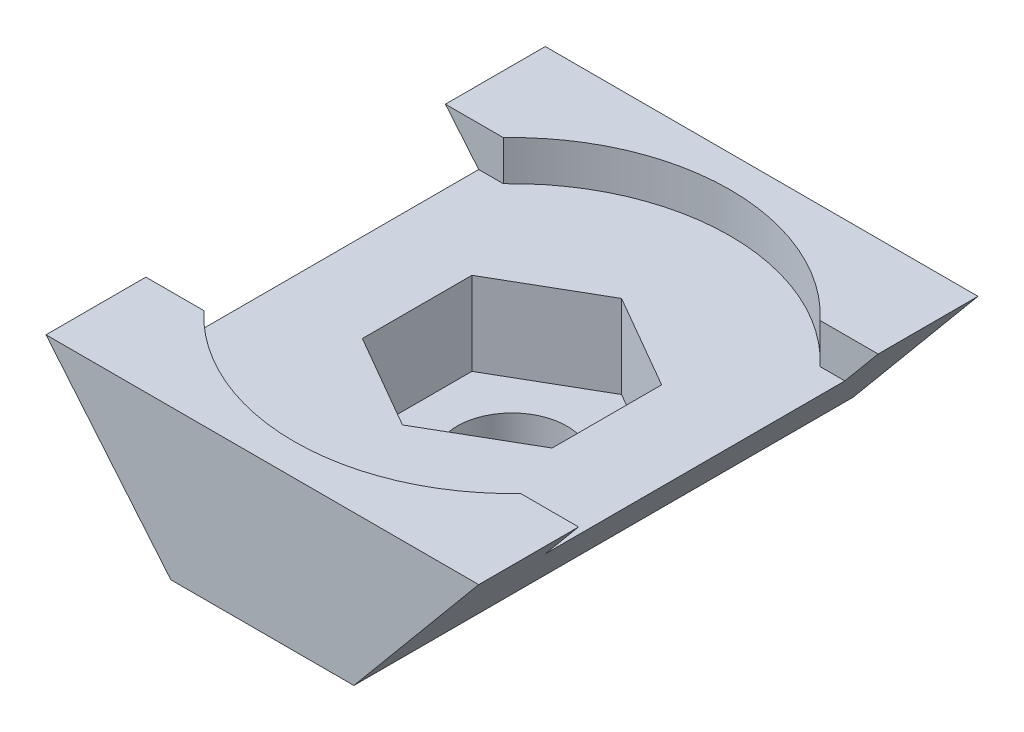
from build123d import *

# Parameters (mm, degrees)
RESSALTO_EXTRUS_O1_DEPTH = 15
ESBO_O2_R                = 1.65
CORTE_EXTRUS_O1_DEPTH    = 15
CORTE_EXTRUS_O5_DEPTH    = 1.2
CORTE_EXTRUS_O6_DEPTH    = 2.5


with BuildPart() as part:
    # Esboço1 → Ressalto-extrusão1 (new body)
    with BuildSketch(Plane.XY):
        Polygon((-6.5, 0), (6.5, 0), (2.75, -4.5), (-2.75, -4.5), align=None)
    extrude(amount=RESSALTO_EXTRUS_O1_DEPTH)

    # Esboço2 → Corte-extrusão1 (cut)
    with BuildSketch(Plane(origin=(0, 0, 0), x_dir=(1, 0, 0), z_dir=(0, 1, 0))):
        with Locations((0, -7.5)):
            Circle(ESBO_O2_R)
    extrude(amount=-CORTE_EXTRUS_O1_DEPTH, mode=Mode.SUBTRACT)

    # Esboço3 → Corte-extrusão5 (cut)
    with BuildSketch(Plane(origin=(0, 0, 0), x_dir=(1, 0, 0), z_dir=(0, 1, 0))):
        with BuildLine():
            Line((4.759464256, -3), (7.813565265, -3))
            Line((7.813565265, -3), (7.813565265, -12))
            Line((7.813565265, -12), (4.759464256, -12))
            ThreePointArc((4.759464256, -12), (0, -14.05), (-4.759464256, -12))
            Line((-4.759464256, -12), (-7.813565265, -12))
            Line((-7.813565265, -12), (-7.813565265, -3))
            Line((-7.813565265, -3), (-4.759464256, -3))
            ThreePointArc((-4.759464256, -3), (0, -0.95), (4.759464256, -3))
        make_face()
    extrude(amount=-CORTE_EXTRUS_O5_DEPTH, mode=Mode.SUBTRACT)

    # Esboço4 → Corte-extrusão6 (cut)
    with BuildSketch(Plane(origin=(0, -1.2, 0), x_dir=(1, 0, 0), z_dir=(0, 1, 0))):
        Polygon((0, -4.209103466), (-2.85, -5.854551733), (-2.85, -9.145448267), (0, -10.790896534), (2.85, -9.145448267), (2.85, -5.854551733), align=None)
    extrude(amount=-CORTE_EXTRUS_O6_DEPTH, mode=Mode.SUBTRACT)


solid = part.part
